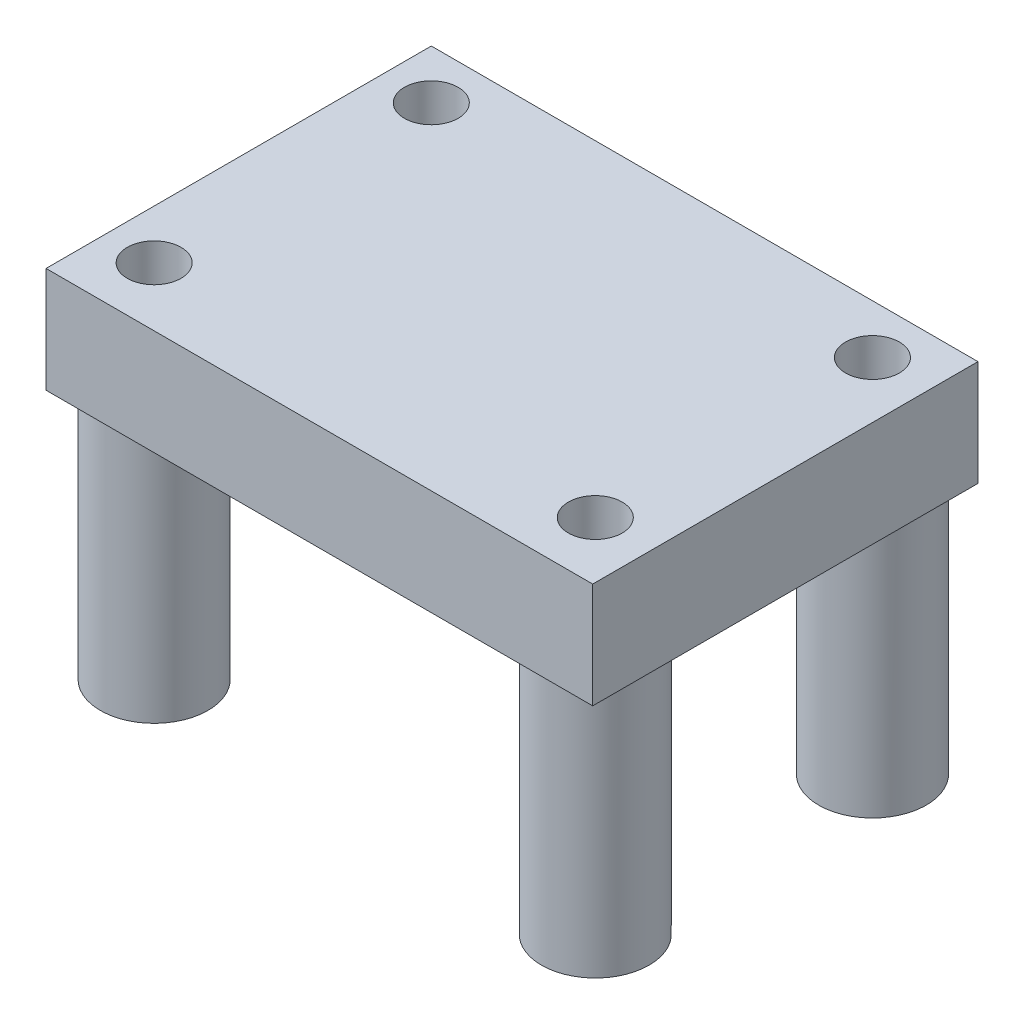
from build123d import *

# Parameters (mm, degrees)
SKETCH1_W           = 25.4
SKETCH1_H           = 17.9
BOSS_EXTRUDE1_DEPTH = 4.9022
SKETCH2_R           = 2.5
BOSS_EXTRUDE2_DEPTH = 11.8618
SKETCH3_R           = 1.25
CUT_EXTRUDE1_DEPTH  = 17.764


with BuildPart() as part:
    # Sketch1 → Boss-Extrude1 (new body)
    with BuildSketch(Plane(origin=(0, 0, 0), x_dir=(1, 0, 0), z_dir=(0, 1, 0))):
        with Locations((-4.163944862, 2.526057393)):
            Rectangle(SKETCH1_W, SKETCH1_H)
    extrude(amount=BOSS_EXTRUDE1_DEPTH)

    # Sketch2 → Boss-Extrude2 (add)
    with BuildSketch(Plane.XZ):
        with Locations((-14.577944862, 3.687742607)):
            Circle(SKETCH2_R)
        with Locations((5.919855138, 3.687742607)):
            Circle(SKETCH2_R)
        with Locations((5.919855138, -9.190057393)):
            Circle(SKETCH2_R)
        with Locations((-14.577944862, -9.190057393)):
            Circle(SKETCH2_R)
    extrude(amount=BOSS_EXTRUDE2_DEPTH)

    # Sketch3 → Cut-Extrude1 (cut, through all)
    with BuildSketch(Plane.XZ.offset(11.8618)):
        with Locations((-14.577944862, 3.687742607)):
            Circle(SKETCH3_R)
        with Locations((-14.577944862, -9.190057393)):
            Circle(SKETCH3_R)
        with Locations((5.919855138, -9.190057393)):
            Circle(SKETCH3_R)
        with Locations((5.919855138, 3.687742607)):
            Circle(SKETCH3_R)
    extrude(amount=-CUT_EXTRUDE1_DEPTH, mode=Mode.SUBTRACT)


solid = part.part
